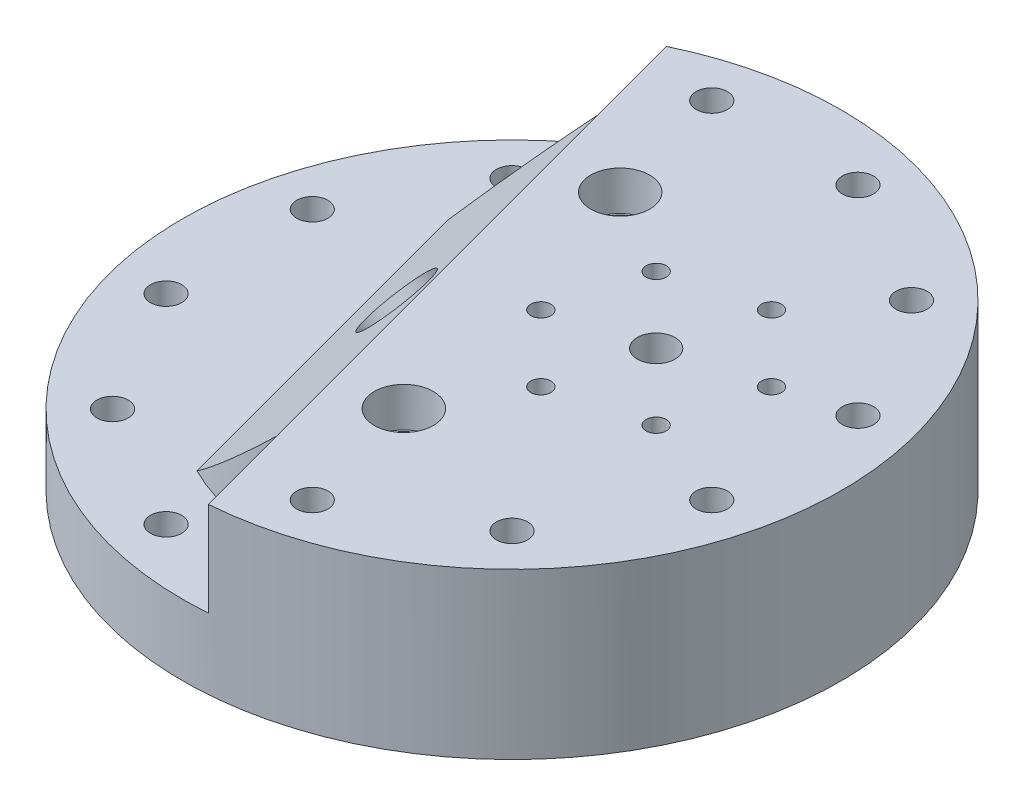
from build123d import *

# Parameters (mm, degrees)
F_5_16_CLEARANCE_HOLE1_D   = 8.4328
CIRPATTERN1_COUNT          = 12
F_1_2_0_4_DIAMETER_HOLE1_D = 10.16
CIRPATTERN2_COUNT          = 6
CUT_EXTRUDE1_DEPTH         = 25.4
CUT_EXTRUDE2_DEPTH         = 136.567701401
CUT_EXTRUDE2_DEPTH_BACK    = 136.567701401
SKETCH36_R                 = 9.7155
SKETCH36_R_2               = 6.6675
CUT_EXTRUDE3_DEPTH         = 2.54


with BuildPart() as part:
    # Sketch1 → Revolve1 (revolve)
    with BuildSketch(Plane.XY):
        Polygon((-54.356, 0), (-88.9, 0), (-88.9, 44.45), (0, 44.45), (0, 19.05), (-14.2875, 19.05), (-14.2875, 6.35), (-20.6375, 6.35), (-20.6375, 0), (-50.8, 0), (-50.8, 2.54), (-54.356, 2.54), align=None)
    revolve(axis=Axis((0, 0, 0), (0, 1, 0)))

    # 5_16 Clearance Hole1 (through all)
    with Locations(Plane(origin=(0, 44.45, 0), x_dir=(1, 0, 0), z_dir=(0, 1, 0))):
        with Locations((-73.603547963, -19.722011237)):
            f_5_16_clearance_hole1 = Hole(F_5_16_CLEARANCE_HOLE1_D / 2)

    # CirPattern1: 5_16 Clearance Hole1 ×12 about axis
    cirpattern1_axis = Axis((0, 0, 0), (0, -1, 0))
    for i in range(1, CIRPATTERN1_COUNT):
        add(f_5_16_clearance_hole1.rotate(cirpattern1_axis, i * 360 / CIRPATTERN1_COUNT), mode=Mode.SUBTRACT)

    # Sketch19 → 3_8 NPT Tapped Hole1 (revolve, cut)
    with BuildSketch(Plane(origin=(10.682756087, 44.45, 39.86858848), x_dir=(0, 0, 1), z_dir=(1, 0, 0))):
        Polygon((0, 0), (0, 44.45), (7.1374, 44.45), (7.1374, 10.414), (7.653732494, 10.414), (7.9655416, 0), align=None)
    f_3_8_npt_tapped_hole1 = revolve(axis=Axis((10.682756087, 50.8, 39.86858848), (0, -1, 0)), mode=Mode.SUBTRACT)

    # Mirror1: 3_8 NPT Tapped Hole1 across plane
    add(f_3_8_npt_tapped_hole1.mirror(Plane(origin=(0, 0, 0), x_dir=(0.9659258262890699, 0, -0.2588190451025147), z_dir=(-0.2588190451025147, 0, -0.96592582628907))), mode=Mode.SUBTRACT)

    # 1_2 _0.4_ Diameter Hole1 (through all)
    with Locations(Plane(origin=(0, 44.45, 0), x_dir=(1, 0, 0), z_dir=(0, 1, 0))):
        with Locations((30.668144985, 8.217504682)):
            Hole(F_1_2_0_4_DIAMETER_HOLE1_D / 2)

    # Sketch30 → Tap Drill for 1_4-28 Tap1 (revolve, cut)
    with BuildSketch(Plane(origin=(55.202660972, 44.45, -14.791508428), x_dir=(0, 0, 1), z_dir=(1, 0, 0))):
        Polygon((0, 0), (0, 17.500388061), (2.7051, 15.875), (2.7051, 0), align=None)
    tap_drill_for_1_4_28_tap1 = revolve(axis=Axis((55.202660972, 50.8, -14.791508428), (0, -1, 0)), mode=Mode.SUBTRACT)

    # CirPattern2: Tap Drill for 1_4-28 Tap1 ×6 about axis
    cirpattern2_axis = Axis((30.668144985, 0, -8.217504682), (0, 1, 0))
    for i in range(1, CIRPATTERN2_COUNT):
        add(tap_drill_for_1_4_28_tap1.rotate(cirpattern2_axis, i * 360 / CIRPATTERN2_COUNT), mode=Mode.SUBTRACT)

    # Sketch31 → Cut-Extrude1 (cut)
    with BuildSketch(Plane(origin=(0, 44.45, 0), x_dir=(1, 0, 0), z_dir=(0, 1, 0))):
        with BuildLine():
            Line((0, -63.5), (6.737403156, -88.644330889))
            ThreePointArc((6.737403156, -88.644330889), (-85.870805957, -23.00901311), (-38.487403156, 80.136944029))
            Line((-38.487403156, 80.136944029), (-31.75, 54.99261314))
            ThreePointArc((-31.75, 54.99261314), (-61.336289969, -16.435009364), (0, -63.5))
        make_face()
    extrude(amount=-CUT_EXTRUDE1_DEPTH, mode=Mode.SUBTRACT)

    # Sketch33 → Cut-Extrude2 (cut, two sides: drawn at the far end of the back side and taken through both)
    with BuildSketch(Plane(origin=(0.700131399, 0, 2.612925953), x_dir=(-0.965925826289068, 0, 0.25881904510252185), z_dir=(-0.25881904510252185, 0, -0.9659258262890681)).offset(-CUT_EXTRUDE2_DEPTH_BACK)):
        Polygon((16.435009364, 44.45), (41.835009364, 19.05), (63.5, 19.05), (63.5, 44.45), align=None)
    extrude(amount=CUT_EXTRUDE2_DEPTH + CUT_EXTRUDE2_DEPTH_BACK, mode=Mode.SUBTRACT)

    # Sketch35 → 1_2 NPT Tapped Hole1 (revolve, cut)
    with BuildSketch(Plane(origin=(-24.549261314, 35.469743879, 6.577954744), x_dir=(-0.3653678270645812, -0.547722557505165, 0.752666161685317), z_dir=(0.6324555320336775, 0.4472135954999533, 0.6324555320336777))):
        Polygon((0, 0), (0, 40.289543693), (8.9281, 34.925), (8.9281, 13.462), (9.479726792, 13.462), (9.8827971, 0), align=None)
    revolve(axis=Axis((-28.886391971, 39.959871939, 7.740085401), (0.6830127018922154, -0.7071067811865513, -0.18301270189221908)), mode=Mode.SUBTRACT)

    # Sketch36 → Cut-Extrude3 (cut)
    with BuildSketch(Plane.XZ):
        with Locations((30.668144985, -8.217504682)):
            Circle(SKETCH36_R)
        with Locations((30.668144985, -8.217504682)):
            Circle(SKETCH36_R_2, mode=Mode.SUBTRACT)
    extrude(amount=-CUT_EXTRUDE3_DEPTH, mode=Mode.SUBTRACT)


solid = part.part
